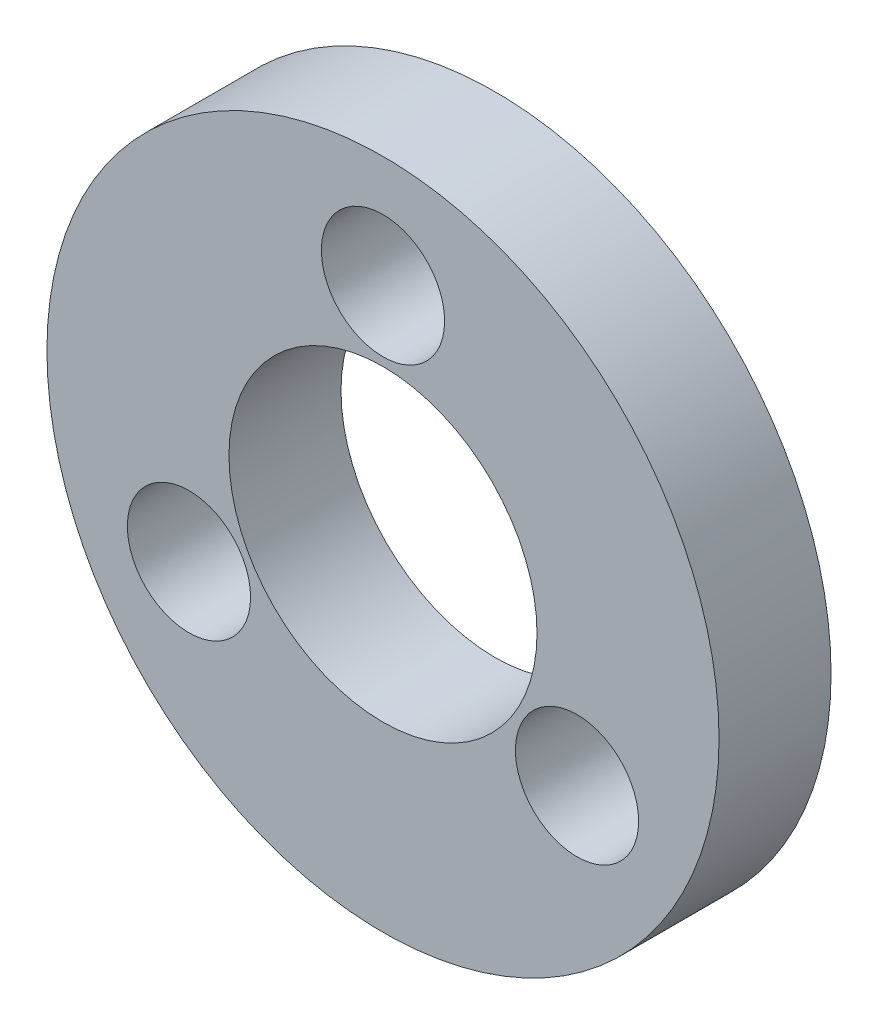
from build123d import *

# Parameters (mm, degrees)
SKETCH1_R            = 6
SKETCH1_R_2          = 2.75
BOSS_EXTRUDE1_DEPTH  = 2
M2_CLEARANCE_HOLE1_D = 2.2


with BuildPart() as part:
    # Sketch1 → Boss-Extrude1 (new body)
    with BuildSketch(Plane.XY):
        with Locations((-27.5, 59.99791663)):
            Circle(SKETCH1_R)
        with Locations((-27.5, 59.99791663)):
            Circle(SKETCH1_R_2, mode=Mode.SUBTRACT)
    extrude(amount=-BOSS_EXTRUDE1_DEPTH)

    # M2 Clearance Hole1 (through all)
    with Locations(Plane.XY):
        with Locations((-27.5, 63.99791663), (-24.035898385, 57.99791663), (-30.964101615, 57.99791663)):
            Hole(M2_CLEARANCE_HOLE1_D / 2)


solid = part.part
